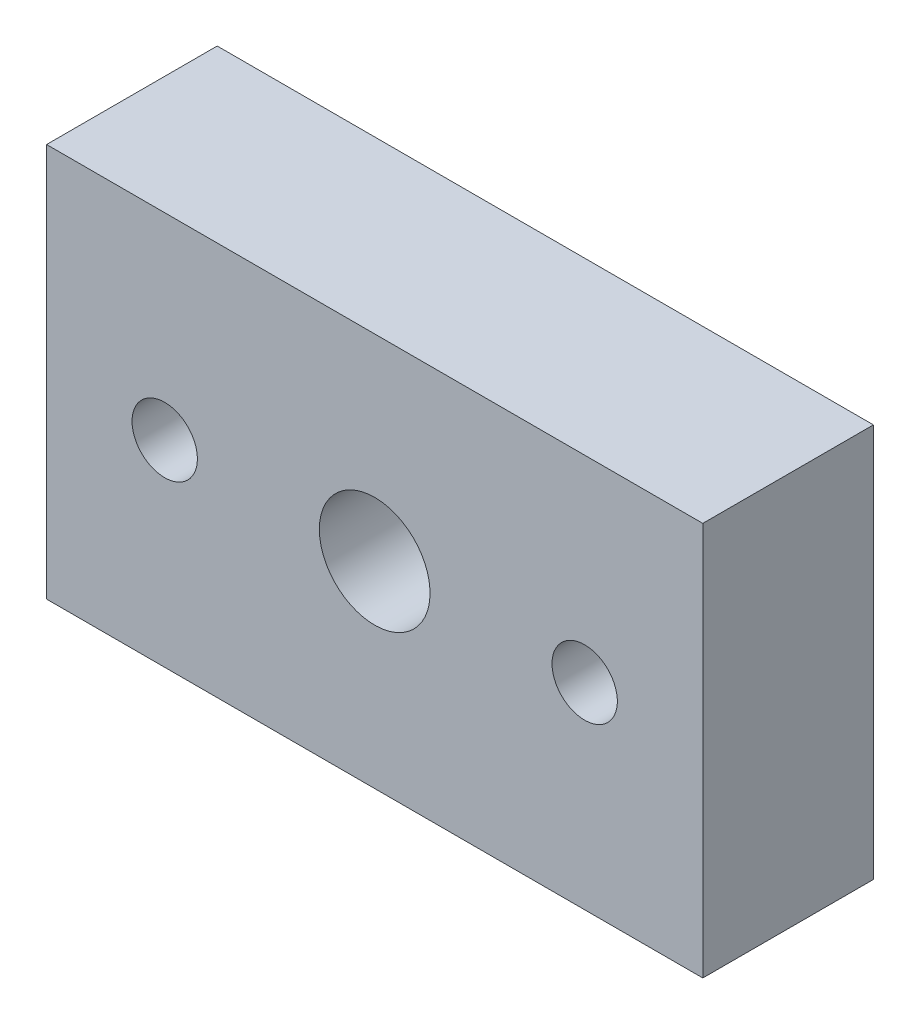
from build123d import *

# Parameters (mm, degrees)
SKETCH1_W                             = 50
SKETCH1_H                             = 30
BOSS_EXTRUDE1_DEPTH                   = 13
TAP_DRILL_FOR_5_16_18_HELICOIL1_D     = 8.4328
TAP_DRILL_FOR_5_16_18_HELICOIL1_DEPTH = 129.53
TAP_DRILL_FOR_5_16_18_HELICOIL1_TIP   = 2.533468714
F_10_CLEARANCE_HOLE1_D                = 4.9784
F_10_CLEARANCE_HOLE1_DEPTH            = 129.53
F_10_CLEARANCE_HOLE1_TIP              = 1.495662253


with BuildPart() as part:
    # Sketch1 → Boss-Extrude1 (new body)
    with BuildSketch(Plane.XY):
        Rectangle(SKETCH1_W, SKETCH1_H)
    extrude(amount=BOSS_EXTRUDE1_DEPTH)

    # Tap Drill for 5/16-18 Helicoil1
    with Locations(Plane(origin=(0, 0, 0), x_dir=(-1, 0, 0), z_dir=(0, 0, -1))):
        with Locations((0, 0)):
            Hole(TAP_DRILL_FOR_5_16_18_HELICOIL1_D / 2, depth=TAP_DRILL_FOR_5_16_18_HELICOIL1_DEPTH)
            with Locations((0, 0, -(TAP_DRILL_FOR_5_16_18_HELICOIL1_DEPTH + TAP_DRILL_FOR_5_16_18_HELICOIL1_TIP / 2))):  # 118° drill point
                Cone(0, TAP_DRILL_FOR_5_16_18_HELICOIL1_D / 2, TAP_DRILL_FOR_5_16_18_HELICOIL1_TIP, mode=Mode.SUBTRACT)

    # #10 Clearance Hole1
    with Locations(Plane(origin=(0, 0, 0), x_dir=(-1, 0, 0), z_dir=(0, 0, -1))):
        with Locations((-16, 0), (16, 0)):
            Hole(F_10_CLEARANCE_HOLE1_D / 2, depth=F_10_CLEARANCE_HOLE1_DEPTH)
            with Locations((0, 0, -(F_10_CLEARANCE_HOLE1_DEPTH + F_10_CLEARANCE_HOLE1_TIP / 2))):  # 118° drill point
                Cone(0, F_10_CLEARANCE_HOLE1_D / 2, F_10_CLEARANCE_HOLE1_TIP, mode=Mode.SUBTRACT)


solid = part.part
